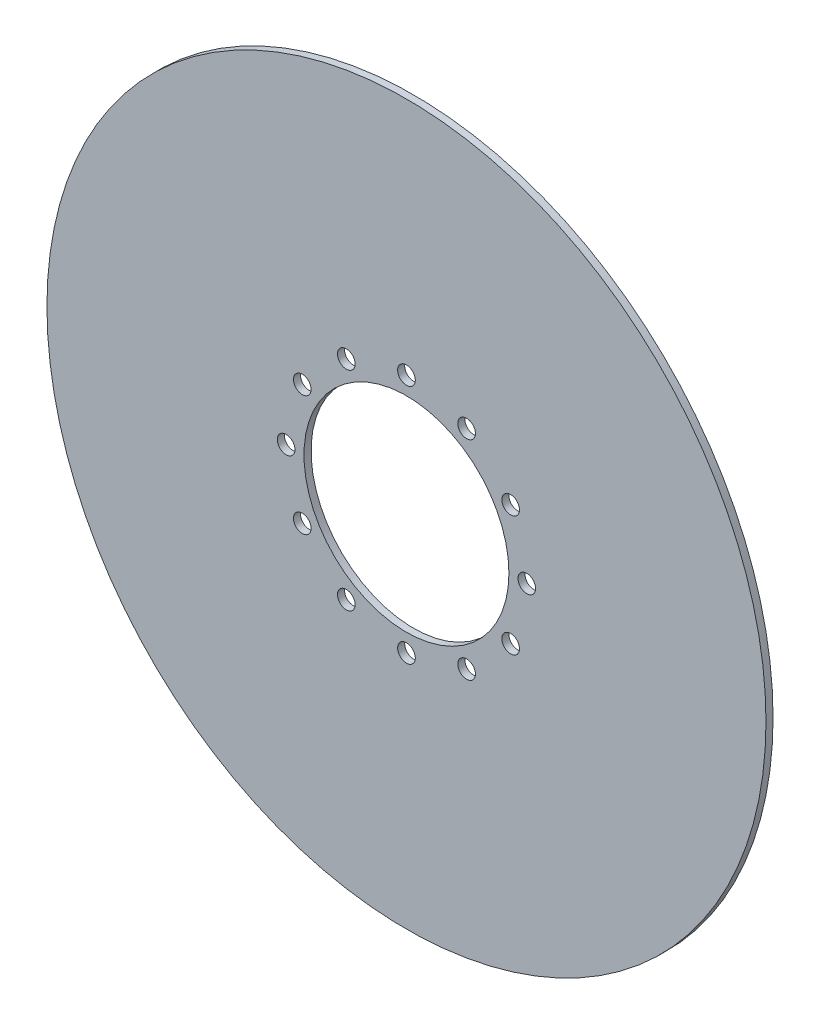
from build123d import *

# Parameters (mm, degrees)
SKETCH1_R           = 101.6
SKETCH1_R_2         = 28.956
SKETCH1_R_3         = 2.49698907
BOSS_EXTRUDE1_DEPTH = 2


with BuildPart() as part:
    # Sketch1 → Boss-Extrude1 (new body)
    with BuildSketch(Plane.XY):
        Circle(SKETCH1_R)
        Circle(SKETCH1_R_2, mode=Mode.SUBTRACT)
        with Locations((0, 34)):
            Circle(SKETCH1_R_3, mode=Mode.SUBTRACT)
        with Locations((17, 29.444863729)):
            Circle(SKETCH1_R_3, mode=Mode.SUBTRACT)
        with Locations((29.444863729, 17)):
            Circle(SKETCH1_R_3, mode=Mode.SUBTRACT)
        with Locations((34, 0)):
            Circle(SKETCH1_R_3, mode=Mode.SUBTRACT)
        with Locations((29.444863729, -17)):
            Circle(SKETCH1_R_3, mode=Mode.SUBTRACT)
        with Locations((17, -29.444863729)):
            Circle(SKETCH1_R_3, mode=Mode.SUBTRACT)
        with Locations((0, -34)):
            Circle(SKETCH1_R_3, mode=Mode.SUBTRACT)
        with Locations((-17, -29.444863729)):
            Circle(SKETCH1_R_3, mode=Mode.SUBTRACT)
        with Locations((-29.444863729, -17)):
            Circle(SKETCH1_R_3, mode=Mode.SUBTRACT)
        with Locations((-34, 0)):
            Circle(SKETCH1_R_3, mode=Mode.SUBTRACT)
        with Locations((-29.444863729, 17)):
            Circle(SKETCH1_R_3, mode=Mode.SUBTRACT)
        with Locations((-17, 29.444863729)):
            Circle(SKETCH1_R_3, mode=Mode.SUBTRACT)
    extrude(amount=BOSS_EXTRUDE1_DEPTH)


solid = part.part
